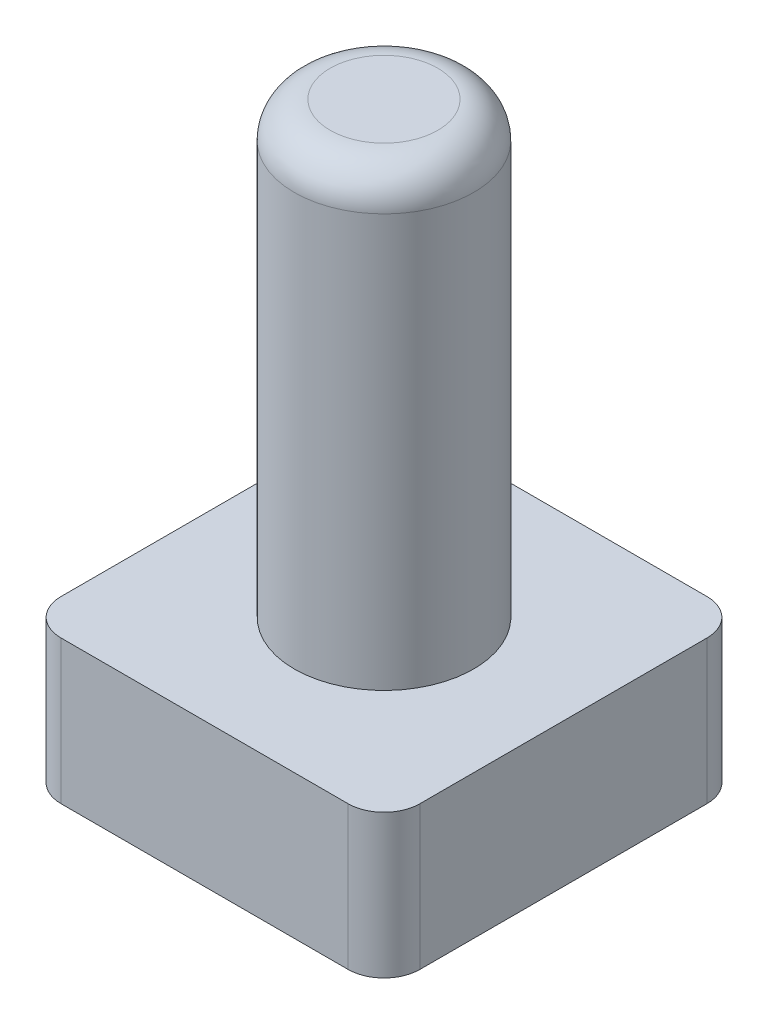
from build123d import *

# Parameters (mm, degrees)
SKETCH1_W           = 10
SKETCH1_H           = 10
SKETCH1_W_2         = 7
SKETCH1_H_2         = 7
BOSS_EXTRUDE1_DEPTH = 3
SKETCH2_W           = 10
SKETCH2_H           = 10
BOSS_EXTRUDE2_DEPTH = 1
SKETCH3_R           = 2.5
BOSS_EXTRUDE3_DEPTH = 12.5
FILLET1_R           = 1


with BuildPart() as part:
    # Sketch1 → Boss-Extrude1 (new body)
    with BuildSketch(Plane(origin=(0, 0, 0), x_dir=(1, 0, 0), z_dir=(0, 1, 0))):
        with Locations((5, 5)):
            Rectangle(SKETCH1_W, SKETCH1_H)
        with Locations((5, 5)):
            Rectangle(SKETCH1_W_2, SKETCH1_H_2, mode=Mode.SUBTRACT)
    extrude(amount=BOSS_EXTRUDE1_DEPTH)

    # Sketch2 → Boss-Extrude2 (add)
    with BuildSketch(Plane(origin=(0, 3, 0), x_dir=(1, 0, 0), z_dir=(0, 1, 0))):
        with Locations((5, 5)):
            Rectangle(SKETCH2_W, SKETCH2_H)
    extrude(amount=BOSS_EXTRUDE2_DEPTH)

    # Sketch3 → Boss-Extrude3 (add)
    with BuildSketch(Plane(origin=(0, 4, 0), x_dir=(1, 0, 0), z_dir=(0, 1, 0))):
        with Locations((5, 5)):
            Circle(SKETCH3_R)
    extrude(amount=BOSS_EXTRUDE3_DEPTH)

    # Fillet1
    fillet1_edges = [part.edges().sort_by_distance(p)[0] for p in [
        (2.5, 16.5, -5),
        (0, 2, -10),
        (10, 2, -10),
        (10, 2, 0),
        (0, 2, 0),
    ]]
    fillet(fillet1_edges, radius=FILLET1_R)


solid = part.part
